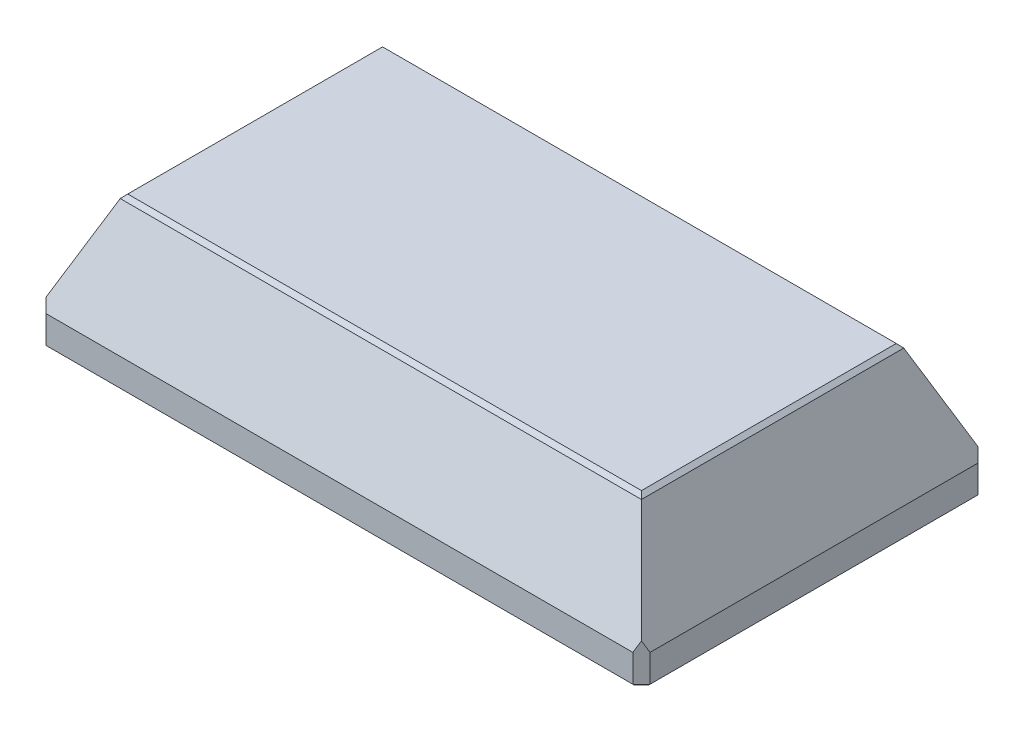
from build123d import *
from OCP.BRepFilletAPI import BRepFilletAPI_MakeChamfer

# Parameters (mm, degrees)
SKETCH1_W                       = 140
SKETCH1_H                       = 80
BOSS_EXTRUDE1_DEPTH             = 7
SKETCH3_W                       = 140
SKETCH3_H                       = 80
SKETCH2_W                       = 120
SKETCH2_H                       = 60
CHAMFER1_SIZE                   = 2
SKETCH4_R                       = 2.05
CUT_EXTRUDE1_DEPTH              = 7
SKETCH5_W                       = 114
SKETCH5_H                       = 50
CUT_EXTRUDE2_DEPTH              = 29
SKETCH6_W                       = 114
SKETCH6_H                       = 62
CUT_EXTRUDE3_DEPTH              = 25
SKETCH7_W                       = 6
SKETCH7_H                       = 62
CUT_EXTRUDE4_DEPTH              = 4
SKETCH8_R                       = 2.05
CUT_EXTRUDE5_DEPTH              = 6
CHAMFER2_SIZE                   = 1
CHAMFER2_SIZE2                  = 0.471497246
CHAMFER3_SIZE                   = 0.6
SKIZZE1_W                       = 54.050484576
SKIZZE1_H                       = 7.5
SKIZZE1_W_2                     = 4
SKIZZE1_H_2                     = 21.453027382
AUFSATZ_LINEAR_AUSTRAGEN1_DEPTH = 10
SKIZZE3_W                       = 29.974757712
SKIZZE3_H                       = 3
SCHNITT_LINEAR_AUSTRAGEN2_DEPTH = 4


with BuildPart() as part:
    # Sketch1 → Boss-Extrude1 (new body)
    with BuildSketch(Plane(origin=(0, 0, 0), x_dir=(1, 0, 0), z_dir=(0, 1, 0))):
        Rectangle(SKETCH1_W, SKETCH1_H)
    extrude(amount=BOSS_EXTRUDE1_DEPTH)

    # Sketch3 → Loft2 section 0
    with BuildSketch(Plane(origin=(0, 7, 0), x_dir=(1, 0, 0), z_dir=(0, 1, 0))):
        Rectangle(SKETCH3_W, SKETCH3_H)
    # Sketch2 → Loft2 section 1
    with BuildSketch(Plane(origin=(0, 30, 0), x_dir=(1, 0, 0), z_dir=(0, 1, 0))):
        Rectangle(SKETCH2_W, SKETCH2_H)
    loft()

    # Chamfer1
    chamfer1_edges = [part.edges().sort_by_distance(p)[0] for p in [
        (-70, 3.5, 40),
        (70, 3.5, 40),
        (70, 3.5, -40),
        (-70, 3.5, -40),
    ]]
    chamfer(chamfer1_edges, length=CHAMFER1_SIZE)

    # Sketch4 → Cut-Extrude1 (cut)
    with BuildSketch(Plane.XZ):
        with Locations(Location((40, -36.5, 0), (0, 0, 270))):
            Circle(SKETCH4_R)
        with Locations(Location((-40, -36.5, 0), (0, 0, 270))):
            Circle(SKETCH4_R)
    cut_extrude1 = extrude(amount=-CUT_EXTRUDE1_DEPTH, mode=Mode.SUBTRACT)

    # Sketch5 → Cut-Extrude2 (cut)
    with BuildSketch(Plane.XZ):
        Rectangle(SKETCH5_W, SKETCH5_H)
    extrude(amount=-CUT_EXTRUDE2_DEPTH, mode=Mode.SUBTRACT)

    # Mirror1: Cut-Extrude1 across plane
    add(cut_extrude1.mirror(Plane.XY), mode=Mode.SUBTRACT)

    # Sketch6 → Cut-Extrude3 (cut)
    with BuildSketch(Plane.XZ):
        Rectangle(SKETCH6_W, SKETCH6_H)
    extrude(amount=-CUT_EXTRUDE3_DEPTH, mode=Mode.SUBTRACT)

    # Sketch7 → Cut-Extrude4 (cut)
    with BuildSketch(Plane.XZ):
        with Locations((-60, 0)):
            Rectangle(SKETCH7_W, SKETCH7_H)
        with Locations((60, 0)):
            Rectangle(SKETCH7_W, SKETCH7_H)
    extrude(amount=-CUT_EXTRUDE4_DEPTH, mode=Mode.SUBTRACT)

    # Sketch8 → Cut-Extrude5 (cut)
    with BuildSketch(Plane.XZ.offset(-4)):
        with Locations(Location((-60, 25, 0), (0, 0, 270))):
            Circle(SKETCH8_R)
        with Locations(Location((-60, -25, 0), (0, 0, 270))):
            Circle(SKETCH8_R)
        with Locations(Location((60, -25, 0), (0, 0, 90))):
            Circle(SKETCH8_R)
        with Locations(Location((60, 25, 0), (0, 0, 90))):
            Circle(SKETCH8_R)
    extrude(amount=-CUT_EXTRUDE5_DEPTH, mode=Mode.SUBTRACT)

    # Chamfer2: one chamfer whose edges measure the first distance from different faces: ONE call of the kernel's chamfer builder (chamfer() names one face for all edges)
    chamfer2_edges_1 = [part.edges().sort_by_distance(p)[0] for p in [
        (60, 30, 0),
    ]]
    chamfer2_side_1 = [part.faces().sort_by_distance(p)[0] for p in [
        (65.225405922, 17.98156638, 0),
    ]]
    chamfer2_edges_2 = [part.edges().sort_by_distance(p)[0] for p in [
        (0, 30, -30),
    ]]
    chamfer2_side_2 = [part.faces().sort_by_distance(p)[0] for p in [
        (0, 18.221212121, -35.121212121),
    ]]
    chamfer2_edges_3 = [part.edges().sort_by_distance(p)[0] for p in [
        (-60, 30, 0),
    ]]
    chamfer2_side_3 = [part.faces().sort_by_distance(p)[0] for p in [
        (-65.225405922, 17.98156638, 0),
    ]]
    chamfer2_edges_4 = [part.edges().sort_by_distance(p)[0] for p in [
        (0, 30, 30),
    ]]
    chamfer2_side_4 = [part.faces().sort_by_distance(p)[0] for p in [
        (0, 18.221212121, 35.121212121),
    ]]
    chamfer2 = BRepFilletAPI_MakeChamfer(part.part.solid().wrapped)
    for e in chamfer2_edges_1:
        chamfer2.Add(CHAMFER2_SIZE, CHAMFER2_SIZE2, e.wrapped, chamfer2_side_1[0].wrapped)  # the first distance lies on this face
    for e in chamfer2_edges_2:
        chamfer2.Add(CHAMFER2_SIZE, CHAMFER2_SIZE2, e.wrapped, chamfer2_side_2[0].wrapped)  # the first distance lies on this face
    for e in chamfer2_edges_3:
        chamfer2.Add(CHAMFER2_SIZE, CHAMFER2_SIZE2, e.wrapped, chamfer2_side_3[0].wrapped)  # the first distance lies on this face
    for e in chamfer2_edges_4:
        chamfer2.Add(CHAMFER2_SIZE, CHAMFER2_SIZE2, e.wrapped, chamfer2_side_4[0].wrapped)  # the first distance lies on this face
    add(Compound.cast(chamfer2.Shape()), mode=Mode.REPLACE)

    # Chamfer3
    chamfer3_edges = [part.edges().sort_by_distance(p)[0] for p in [
        (0, 0, 40),
        (70, 0, 0),
        (-70, 0, 0),
        (0, 0, -40),
        (-69, 0, -39),
        (69, 0, -39),
        (69, 0, 39),
        (-69, 0, 39),
    ]]
    chamfer(chamfer3_edges, length=CHAMFER3_SIZE)

    # Skizze1 → Aufsatz-Linear austragen1 (add)
    with BuildSketch(Plane.XZ.offset(-29)):
        with Locations((0, -21.25)):
            Rectangle(SKIZZE1_W, SKIZZE1_H)
        with Locations((0, 21.25)):
            Rectangle(SKIZZE1_W, SKIZZE1_H)
        with Locations((55, 0)):
            Rectangle(SKIZZE1_W_2, SKIZZE1_H_2)
    extrude(amount=AUFSATZ_LINEAR_AUSTRAGEN1_DEPTH)

    # Skizze3 → Schnitt-Linear austragen2 (cut)
    with BuildSketch(Plane(origin=(0, 29, 0), x_dir=(-1, 0, 0), z_dir=(0, -1, 0))):
        with Locations((42.012621144, -26.5)):
            Rectangle(SKIZZE3_W, SKIZZE3_H)
        with Locations((-42.012621144, -26.5)):
            Rectangle(SKIZZE3_W, SKIZZE3_H)
        with Locations((42.012621144, 26.5)):
            Rectangle(SKIZZE3_W, SKIZZE3_H)
        with Locations((-42.012621144, 26.5)):
            Rectangle(SKIZZE3_W, SKIZZE3_H)
    extrude(amount=SCHNITT_LINEAR_AUSTRAGEN2_DEPTH, mode=Mode.SUBTRACT)


solid = part.part
